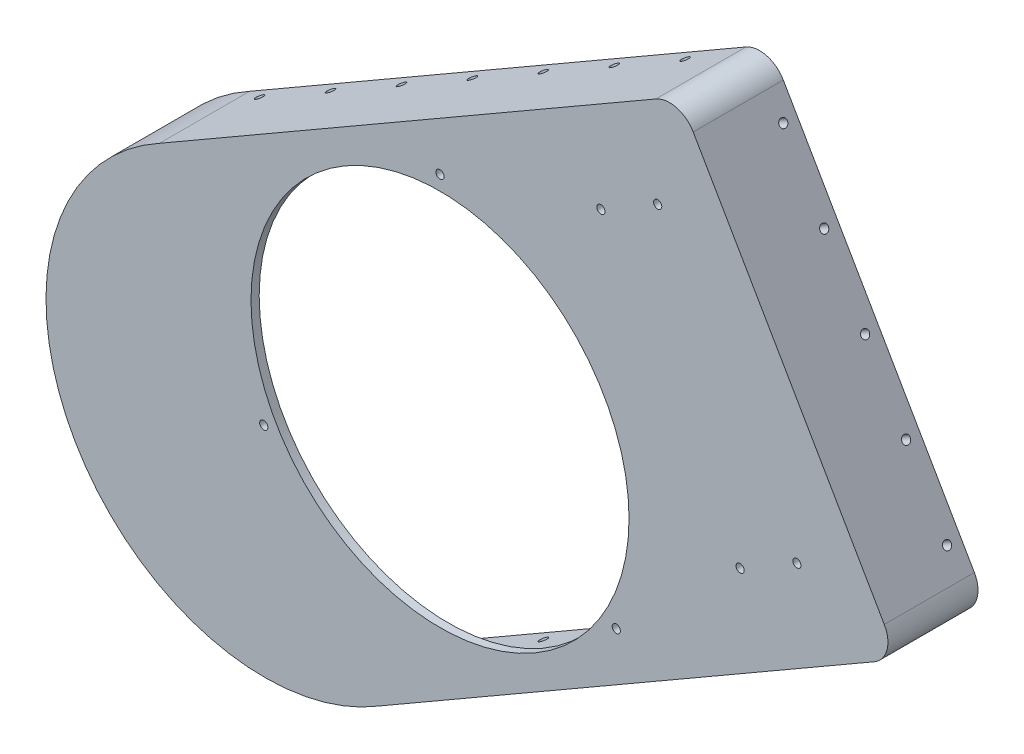
from build123d import *
from build123d.topology import SkipClean

# Parameters (mm, degrees)
SKETCH_1_R           = 1.5
SKETCH_1_R_2         = 69.25
EXTRUDE_1_DEPTH      = 3
SKETCH_2_R           = 1.5
CUT_EXTRUDE_1_DEPTH  = 10
EXTRUDE_4_DEPTH      = 30
SKETCH_21_R          = 1.5
CUT_EXTRUDE_16_DEPTH = 279.057392773
SKETCH_22_R          = 1.5
CUT_EXTRUDE_17_DEPTH = 15


with BuildPart() as part:
    # 草图1 → 凸台-拉伸1 (new body)
    with BuildSketch(Plane.XY):
        with BuildLine():
            Line((-22.769302312, -105.521905889), (96.897661611, -36.432152055))
            Line((96.897661611, -36.432152055), (159.096032483, -0.521905889))
            ThreePointArc((159.096032483, -0.521905889), (163.755290746, 5.550157697), (162.756286521, 13.138348148))
            Line((162.756286521, 13.138348148), (92.756286521, 134.381904678))
            ThreePointArc((92.756286521, 134.381904678), (86.684222934, 139.041162941), (79.096032483, 138.042158716))
            Line((79.096032483, 138.042158716), (16.897661611, 102.13191255))
            Line((16.897661611, 102.13191255), (-102.769302312, 33.042158716))
            ThreePointArc((-102.769302312, 33.042158716), (-133.627927222, -77.150119753), (-22.769302312, -105.521905889))
        make_face()
        with Locations((0, 74.563800918)):
            Circle(SKETCH_1_R, mode=Mode.SUBTRACT)
        with Locations((64.574145798, -37.281900459)):
            Circle(SKETCH_1_R, mode=Mode.SUBTRACT)
        with Locations((-64.574145798, -37.281900459)):
            Circle(SKETCH_1_R, mode=Mode.SUBTRACT)
        Circle(SKETCH_1_R_2, mode=Mode.SUBTRACT)
    extrude(amount=EXTRUDE_1_DEPTH)

    # 草图2 → 切除-拉伸1 (cut)
    with BuildSketch(Plane(origin=(0, 0, 0), x_dir=(-1, 0, 0), z_dir=(0, 0, -1))):
        with Locations((-109.955016331, 4.59283082)):
            Circle(SKETCH_2_R)
        with Locations((-130.739626022, 16.59283082)):
            Circle(SKETCH_2_R)
        with Locations(Location((-58.955016331, 92.927422006, 0), (0, 0, 180))):
            Circle(SKETCH_2_R)
        with Locations(Location((-79.739626022, 104.927422006, 0), (0, 0, 180))):
            Circle(SKETCH_2_R)
    extrude(amount=-CUT_EXTRUDE_1_DEPTH, mode=Mode.SUBTRACT)

    # 草图20 → 凸台-拉伸4 (add)
    with SkipClean():  # the faces are left unmerged after this step: merging them gives an invalid solid
        with BuildSketch(Plane(origin=(0, 0, 0), x_dir=(-1, 0, 0), z_dir=(0, 0, -1))):
            with BuildLine():
                Line((-92.756286521, 134.381904678), (-162.756286521, 13.138348148))
                ThreePointArc((-162.756286521, 13.138348148), (-163.755290746, 5.550157697), (-159.096032483, -0.521905889))
                Line((-159.096032483, -0.521905889), (22.769302312, -105.521905889))
                ThreePointArc((22.769302312, -105.521905889), (133.627927222, -77.150119753), (102.769302312, 33.042158716))
                Line((102.769302312, 33.042158716), (-79.096032483, 138.042158716))
                ThreePointArc((-79.096032483, 138.042158716), (-86.684222934, 139.041162941), (-92.756286521, 134.381904678))
            make_face()
            with BuildLine():
                Line((-89.292184905, 132.381904678), (-159.292184905, 11.138348148))
                ThreePointArc((-159.292184905, 11.138348148), (-159.89158744, 6.585433878), (-157.096032483, 2.942195726))
                Line((-157.096032483, 2.942195726), (24.808773358, -102.080592893))
                ThreePointArc((24.808773358, -102.080592893), (130.163825607, -75.150119753), (100.808773358, 29.555268482))
                Line((100.808773358, 29.555268482), (-81.096032483, 134.578057101))
                ThreePointArc((-81.096032483, 134.578057101), (-85.648946753, 135.177459636), (-89.292184905, 132.381904678))
            make_face(mode=Mode.SUBTRACT)
        extrude(amount=EXTRUDE_4_DEPTH)

    # 草图21 → 切除-拉伸16 (cut, through all)
    with SkipClean():  # the faces are left unmerged after this step: merging them gives an invalid solid
        with BuildSketch(Plane(origin=(-40, 69.282032303, 0), x_dir=(0.8660254037844386, 0.4999999999999999, 0), z_dir=(-0.49999999999999994, 0.8660254037844387, 0))):
            with Locations(Location((-62.479747173, 25, 0), (0, 0, 180))):
                Circle(SKETCH_21_R)
            with Locations(Location((-32.479747173, 25, 0), (0, 0, 180))):
                Circle(SKETCH_21_R)
            with Locations(Location((-2.479747173, 25, 0), (0, 0, 180))):
                Circle(SKETCH_21_R)
            with Locations(Location((27.520252827, 25, 0), (0, 0, 180))):
                Circle(SKETCH_21_R)
            with Locations(Location((57.520252827, 25, 0), (0, 0, 180))):
                Circle(SKETCH_21_R)
            with Locations(Location((87.520252827, 25, 0), (0, 0, 180))):
                Circle(SKETCH_21_R)
            with Locations(Location((117.520252827, 25, 0), (0, 0, 180))):
                Circle(SKETCH_21_R)
        extrude(amount=-CUT_EXTRUDE_16_DEPTH, mode=Mode.SUBTRACT)

    # 草图22 → 切除-拉伸17 (cut)
    with SkipClean():  # the faces are left unmerged after this step: merging them gives an invalid solid
        with BuildSketch(Plane(origin=(127.756286521, 73.760126413, 0), x_dir=(0, 0, -1), z_dir=(0.8660254037844386, 0.5000000000000001, 0))):
            with Locations(Location((25, 60, 0), (0, 0, 90))):
                Circle(SKETCH_22_R)
            with Locations(Location((25, 30, 0), (0, 0, 90))):
                Circle(SKETCH_22_R)
            with Locations(Location((25, 0, 0), (0, 0, 90))):
                Circle(SKETCH_22_R)
            with Locations(Location((25, -30, 0), (0, 0, 90))):
                Circle(SKETCH_22_R)
            with Locations(Location((25, -60, 0), (0, 0, 90))):
                Circle(SKETCH_22_R)
        extrude(amount=-CUT_EXTRUDE_17_DEPTH, mode=Mode.SUBTRACT)


solid = part.part
